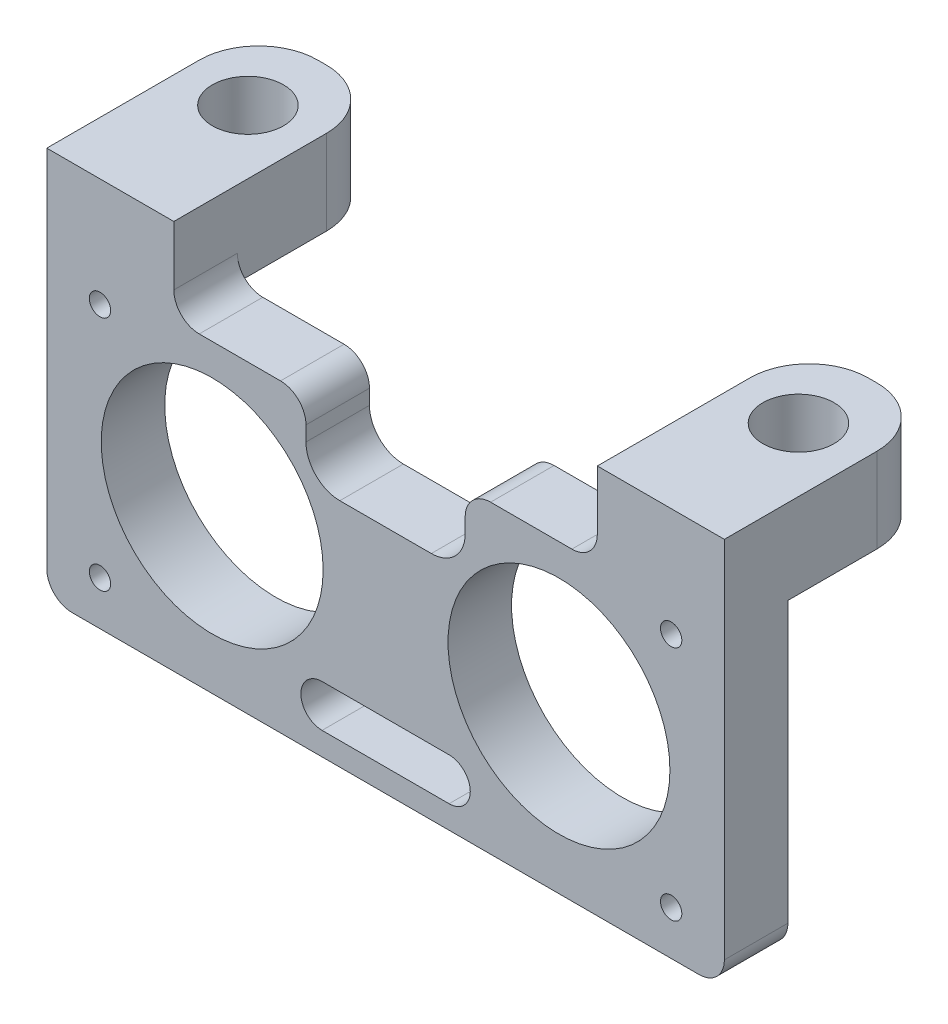
from build123d import *

# Parameters (mm, degrees)
SKETCH10_R          = 0.8
SKETCH10_R_2        = 8.3185
BOSS_EXTRUDE1_DEPTH = 4.7625
SKETCH11_W          = 9.525
SKETCH11_H          = 15.875
BOSS_EXTRUDE2_DEPTH = 6.35
FILLET1_R           = 1.905
SKETCH12_R          = 2.667
CUT_EXTRUDE1_DEPTH  = 7.35
FILLET2_R           = 4.445
CHAMFER1_SIZE       = 1.27


with BuildPart() as part:
    # Sketch10 → Boss-Extrude1 (new body)
    with BuildSketch(Plane.XY):
        with BuildLine():
            Line((5.969, 19.548), (5.969, 16.531104381))
            ThreePointArc((5.969, 16.531104381), (5.225051224, 14.735053157), (3.429, 13.991104381))
            Line((3.429, 13.991104381), (-3.429, 13.991104381))
            ThreePointArc((-3.429, 13.991104381), (-5.225051224, 14.735053157), (-5.969, 16.531104381))
            Line((-5.969, 16.531104381), (-5.969, 19.548))
            Line((-5.969, 19.548), (-25.4, 19.548))
            Line((-25.4, 19.548), (-25.4, -3.312))
            Line((-25.4, -3.312), (25.4, -3.312))
            Line((25.4, -3.312), (25.4, 19.548))
            Line((25.4, 19.548), (5.969, 19.548))
        make_face()
        with Locations((21.41, 17.74)):
            Circle(SKETCH10_R, mode=Mode.SUBTRACT)
        with Locations((21.41, 0)):
            Circle(SKETCH10_R, mode=Mode.SUBTRACT)
        with Locations((-21.41, 17.74)):
            Circle(SKETCH10_R, mode=Mode.SUBTRACT)
        with Locations((-21.41, 0)):
            Circle(SKETCH10_R, mode=Mode.SUBTRACT)
        with Locations((13, 8.87)):
            Circle(SKETCH10_R_2, mode=Mode.SUBTRACT)
        with Locations((-13, 8.87)):
            Circle(SKETCH10_R_2, mode=Mode.SUBTRACT)
        with BuildLine():
            Line((-4.7625, 1.5875), (4.7625, 1.5875))
            ThreePointArc((4.7625, 1.5875), (6.35, 0), (4.7625, -1.5875))
            Line((4.7625, -1.5875), (-4.7625, -1.5875))
            ThreePointArc((-4.7625, -1.5875), (-6.35, 0), (-4.7625, 1.5875))
        make_face(mode=Mode.SUBTRACT)
    extrude(amount=BOSS_EXTRUDE1_DEPTH)

    # Sketch11 → Boss-Extrude2 (add)
    with BuildSketch(Plane.XZ.offset(-19.548)):
        with Locations((20.6375, -3.175)):
            Rectangle(SKETCH11_W, SKETCH11_H)
        with Locations((-20.6375, -3.175)):
            Rectangle(SKETCH11_W, SKETCH11_H)
    extrude(amount=-BOSS_EXTRUDE2_DEPTH)

    # Fillet1
    fillet1_edges = [part.edges().sort_by_distance(p)[0] for p in [
        (25.4, -3.312, 2.38125),
        (-25.4, -3.312, 2.38125),
        (-5.969, 19.548, 2.38125),
        (5.969, 19.548, 2.38125),
        (15.875, 19.548, 2.38125),
        (-15.875, 19.548, 2.38125),
    ]]
    fillet(fillet1_edges, radius=FILLET1_R)

    # Sketch12 → Cut-Extrude1 (cut, through all)
    with BuildSketch(Plane.XZ.offset(-19.548)):
        with Locations((-20.6375, -5.55625)):
            Circle(SKETCH12_R)
        with Locations((20.6375, -5.55625)):
            Circle(SKETCH12_R)
    extrude(amount=-CUT_EXTRUDE1_DEPTH, mode=Mode.SUBTRACT)

    # Fillet2
    fillet2_edges = [part.edges().sort_by_distance(p)[0] for p in [
        (25.4, 22.723, -11.1125),
        (15.875, 22.723, -11.1125),
        (-15.875, 22.723, -11.1125),
        (-25.4, 22.723, -11.1125),
    ]]
    fillet(fillet2_edges, radius=FILLET2_R)

    # Chamfer1
    chamfer1_edges = [part.edges().sort_by_distance(p)[0] for p in [
        (-23.3045, 19.548, -5.55625),
        (17.9705, 19.548, -5.55625),
    ]]
    chamfer(chamfer1_edges, length=CHAMFER1_SIZE)


solid = part.part
